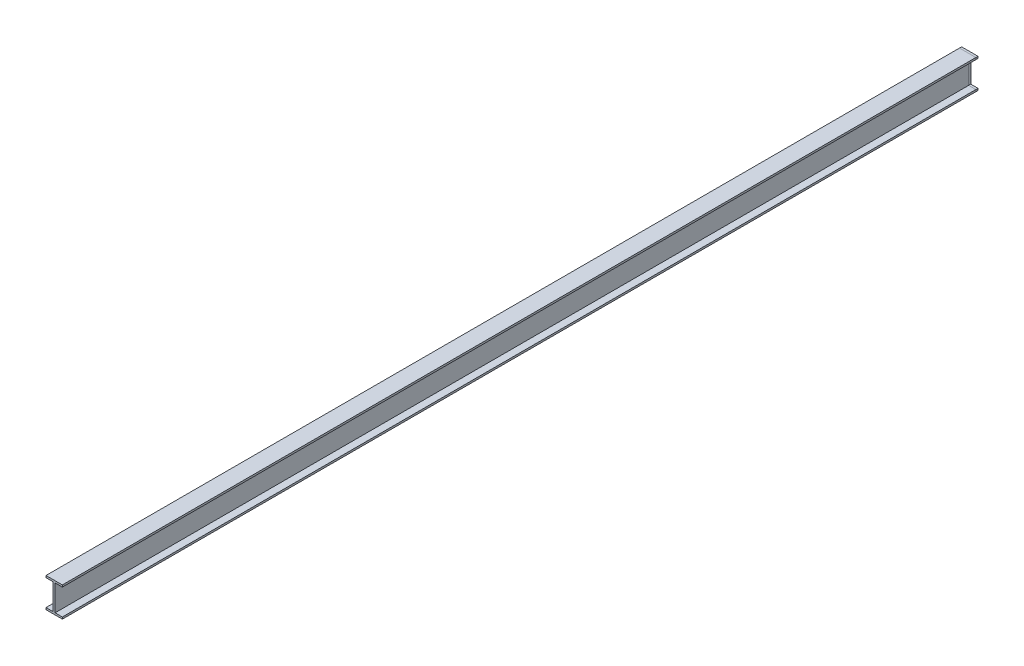
from build123d import *

# Parameters (mm, degrees)
SKETCH2_W           = 5.715
SKETCH2_H           = 154.94
BOSS_EXTRUDE1_DEPTH = 5486.4


with BuildPart() as part:
    # Sketch2 → Boss-Extrude1 (new body)
    with BuildSketch(Plane.XY):
        Polygon((-5.715, 166.37), (0, 166.37), (0, 177.8), (-49.022, 177.8), (-49.022, 166.37), align=None)
        Polygon((0, 177.8), (0, 166.37), (5.715, 166.37), (49.022, 166.37), (49.022, 177.8), align=None)
        with Locations((2.8575, 88.9)):
            Rectangle(SKETCH2_W, SKETCH2_H)
        with Locations((-2.8575, 88.9)):
            Rectangle(SKETCH2_W, SKETCH2_H)
        Polygon((-49.022, 11.43), (-49.022, 0), (0, 0), (0, 11.43), (-5.715, 11.43), align=None)
        Polygon((0, 11.43), (0, 0), (49.022, 0), (49.022, 11.43), (5.715, 11.43), align=None)
    extrude(amount=BOSS_EXTRUDE1_DEPTH)


solid = part.part
